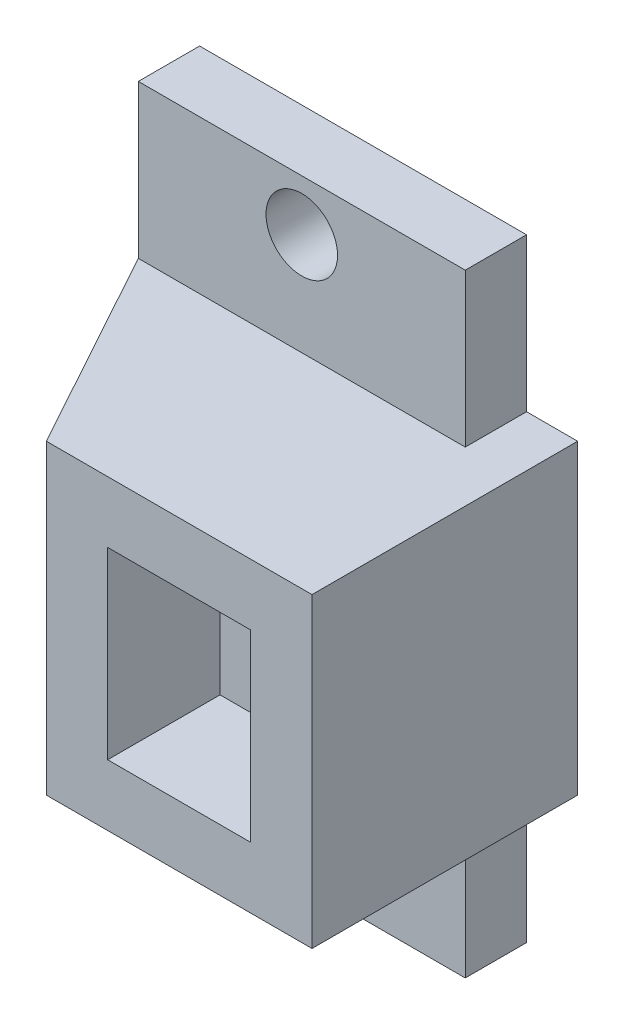
from build123d import *

# Parameters (mm, degrees)
ESQUISSE1_R        = 1.75
BOSS_EXTRU_1_DEPTH = 3
ESQUISSE1_3_W      = 7
ESQUISSE1_3_H      = 9
BOSS_EXTRU_2_DEPTH = 13
NERVURE2_REACH     = 30.623
ESQUISSE5_WALL_W   = 70.657799336
ESQUISSE5_WALL_H   = 3
ESQUISSE1_4_W      = 7
ESQUISSE1_4_H      = 9
BOSS_EXTRU_3_DEPTH = 7.5


with BuildPart() as part:
    # Esquisse1 → Boss.-Extru.1 (new body)
    with BuildSketch(Plane.XY):
        Polygon((-6.5, -7.5), (-6.5, 7.5), (4, 7.5), (4, 15), (-12, 15), (-12, -15), (4, -15), (4, -7.5), align=None)
        with Locations((-9.25, 0)):
            Circle(ESQUISSE1_R, mode=Mode.SUBTRACT)
        with Locations((-4, -12.5)):
            Circle(ESQUISSE1_R, mode=Mode.SUBTRACT)
        with Locations((-4, 12.5)):
            Circle(ESQUISSE1_R, mode=Mode.SUBTRACT)
    extrude(amount=BOSS_EXTRU_1_DEPTH)

    # Esquisse1_3 → Boss.-Extru.2 (add)
    with BuildSketch(Plane.XY):
        Polygon((4, 7.5), (-6.5, 7.5), (-6.5, -7.5), (4, -7.5), (6.5, -7.5), (6.5, 7.5), align=None)
        Rectangle(ESQUISSE1_3_W, ESQUISSE1_3_H, mode=Mode.SUBTRACT)
    extrude(amount=BOSS_EXTRU_2_DEPTH)

    # Esquisse5 wall → Nervure2 (add, up to next)
    with BuildSketch(Plane(origin=(-9.25, -7.5, 8), x_dir=(-0.481918749772, 0, -0.876215908677), z_dir=(0.876215908677, 0, -0.481918749772)), mode=Mode.PRIVATE) as nervure2_sk1:
        with Locations((0, 1.5)):
            Rectangle(ESQUISSE5_WALL_W, ESQUISSE5_WALL_H)
    nervure2_tool1 = extrude(nervure2_sk1.sketch, amount=NERVURE2_REACH, mode=Mode.PRIVATE) - part.part
    nervure2 = nervure2_tool1.solids().sort_by_distance((-9.25, -7.5, 8))[0]
    add(nervure2)

    # Symétrie4: Nervure2 across plane
    add(nervure2.mirror(Plane.ZX))

    # Esquisse1_4 → Boss.-Extru.3 (add)
    with BuildSketch(Plane.XY):
        Rectangle(ESQUISSE1_4_W, ESQUISSE1_4_H)
    extrude(amount=BOSS_EXTRU_3_DEPTH)


solid = part.part
